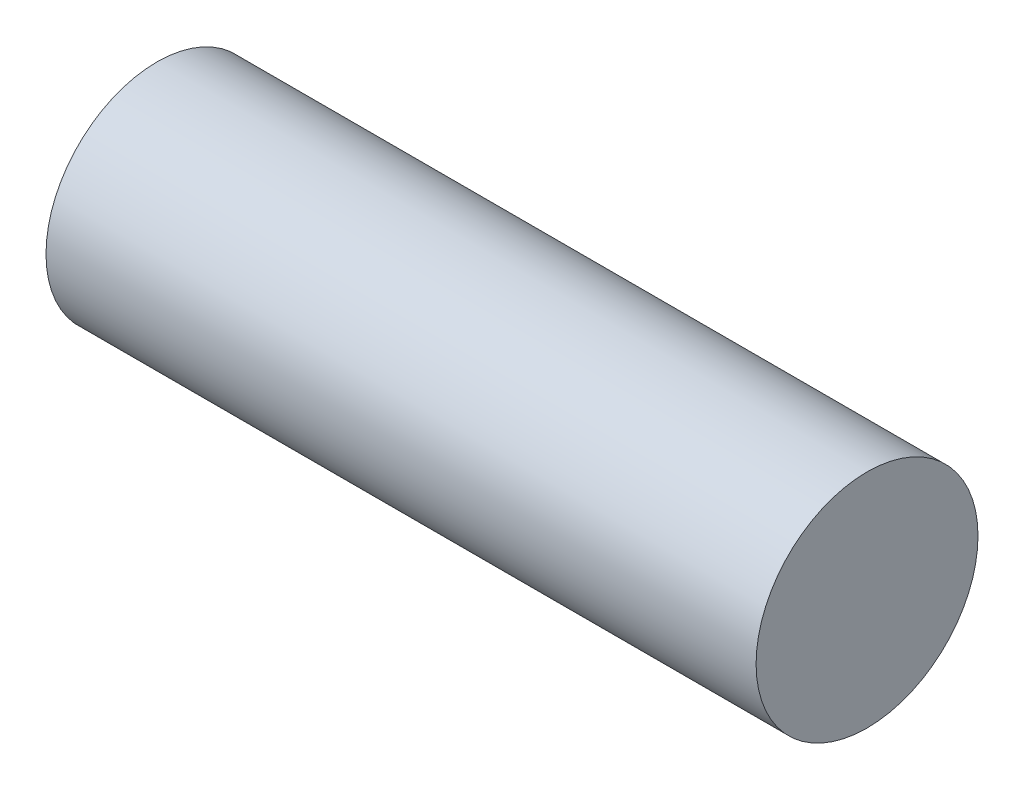
from build123d import *

# Parameters (mm, degrees)
SKETCH1_R           = 2.5
BOSS_EXTRUDE1_DEPTH = 16


with BuildPart() as part:
    # Sketch1 → Boss-Extrude1 (new body)
    with BuildSketch(Plane(origin=(0, 0, 0), x_dir=(0, 0, -1), z_dir=(1, 0, 0))):
        Circle(SKETCH1_R)
    extrude(amount=BOSS_EXTRUDE1_DEPTH)


solid = part.part
